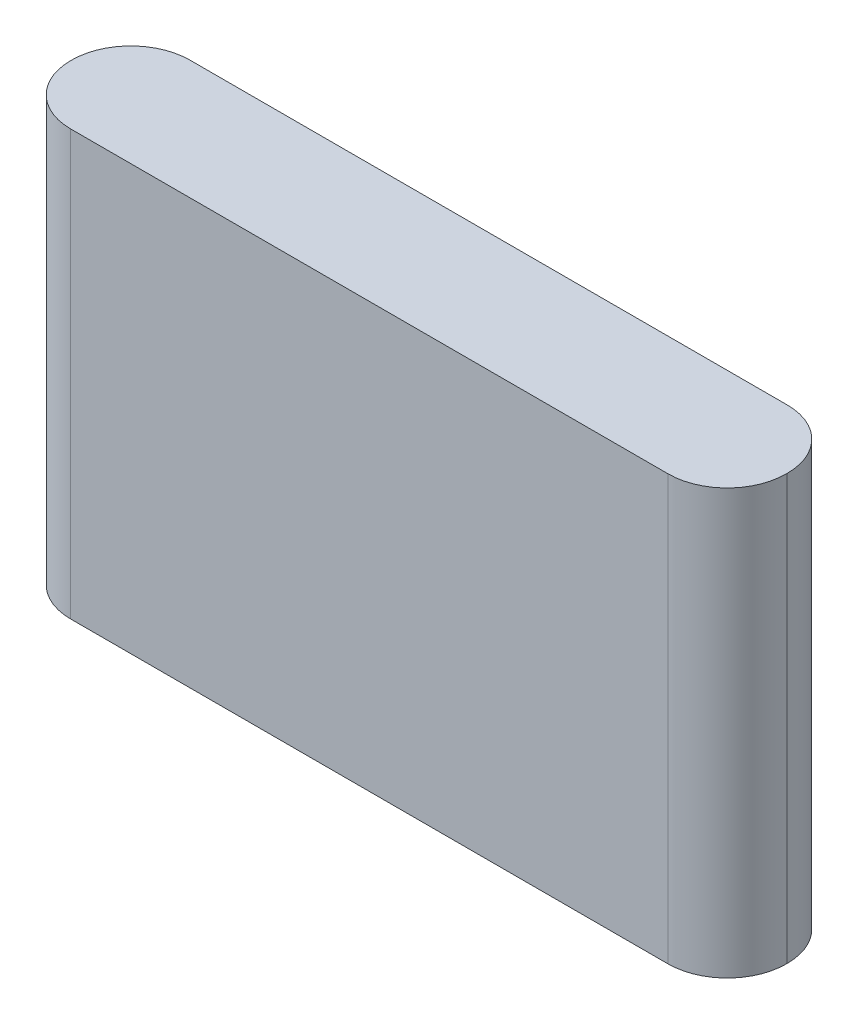
from build123d import *

# Parameters (mm, degrees)
SKETCH1_W           = 86
SKETCH1_H           = 14.33
BOSS_EXTRUDE1_DEPTH = 51
FILLET1_R           = 7.1


with BuildPart() as part:
    # Sketch1 → Boss-Extrude1 (new body)
    with BuildSketch(Plane(origin=(0, 0, 0), x_dir=(1, 0, 0), z_dir=(0, 1, 0))):
        Rectangle(SKETCH1_W, SKETCH1_H)
    extrude(amount=BOSS_EXTRUDE1_DEPTH)

    # Fillet1
    fillet1_edges = [part.edges().sort_by_distance(p)[0] for p in [
        (43, 25.5, 7.165),
        (-43, 25.5, 7.165),
        (-43, 25.5, -7.165),
        (43, 25.5, -7.165),
    ]]
    fillet(fillet1_edges, radius=FILLET1_R)


solid = part.part
